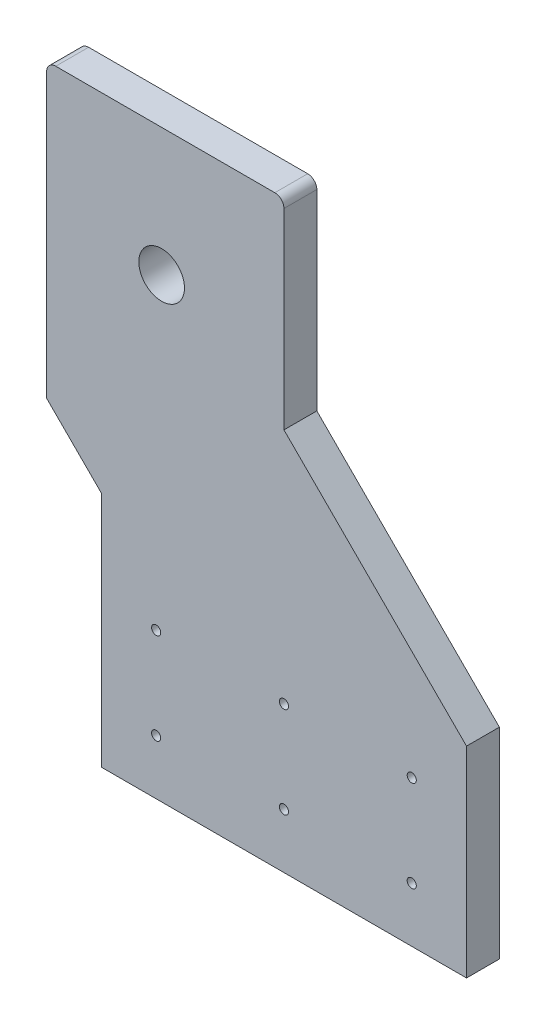
from build123d import *

# Parameters (mm, degrees)
SKETCH1_R                      = 12.5
BOSS_EXTRUDE1_DEPTH            = 18
HOLE_FOR_M5_300_SC_NUTS_SP_1_D = 5


with BuildPart() as part:
    # Sketch1 → Boss-Extrude1 (new body)
    with BuildSketch(Plane.XY):
        with BuildLine():
            Line((4.070181983, 148.487708827), (4.070181983, 43.487708827))
            Line((4.070181983, 43.487708827), (104.070181983, -56.512291173))
            Line((104.070181983, -56.512291173), (104.070181983, -166.512291173))
            Line((104.070181983, -166.512291173), (-95.929818017, -166.512291173))
            Line((-95.929818017, -166.512291173), (-95.929818017, -36.512291173))
            Line((-95.929818017, -36.512291173), (-125.929818017, -6.512291173))
            Line((-125.929818017, -6.512291173), (-125.929818017, 148.487708827))
            ThreePointArc((-125.929818017, 148.487708827), (-124.465351923, 152.023242733), (-120.929818017, 153.487708827))
            Line((-120.929818017, 153.487708827), (-95.929818017, 153.487708827))
            Line((-95.929818017, 153.487708827), (-0.929818017, 153.487708827))
            ThreePointArc((-0.929818017, 153.487708827), (2.605715889, 152.023242733), (4.070181983, 148.487708827))
        make_face()
        with Locations((-62.929818017, 83.487708827)):
            Circle(SKETCH1_R, mode=Mode.SUBTRACT)
    extrude(amount=BOSS_EXTRUDE1_DEPTH)

    # Hole for M5 300® SC Nuts (SP)1 (through all)
    with Locations(Plane.XY.offset(18)):
        with Locations((74.070181983, -86.512291173), (74.070181983, -136.512291173), (4.070181983, -136.512291173), (-65.929818017, -136.512291173), (-65.929818017, -86.512291173), (4.070181983, -86.512291173)):
            Hole(HOLE_FOR_M5_300_SC_NUTS_SP_1_D / 2)


solid = part.part
